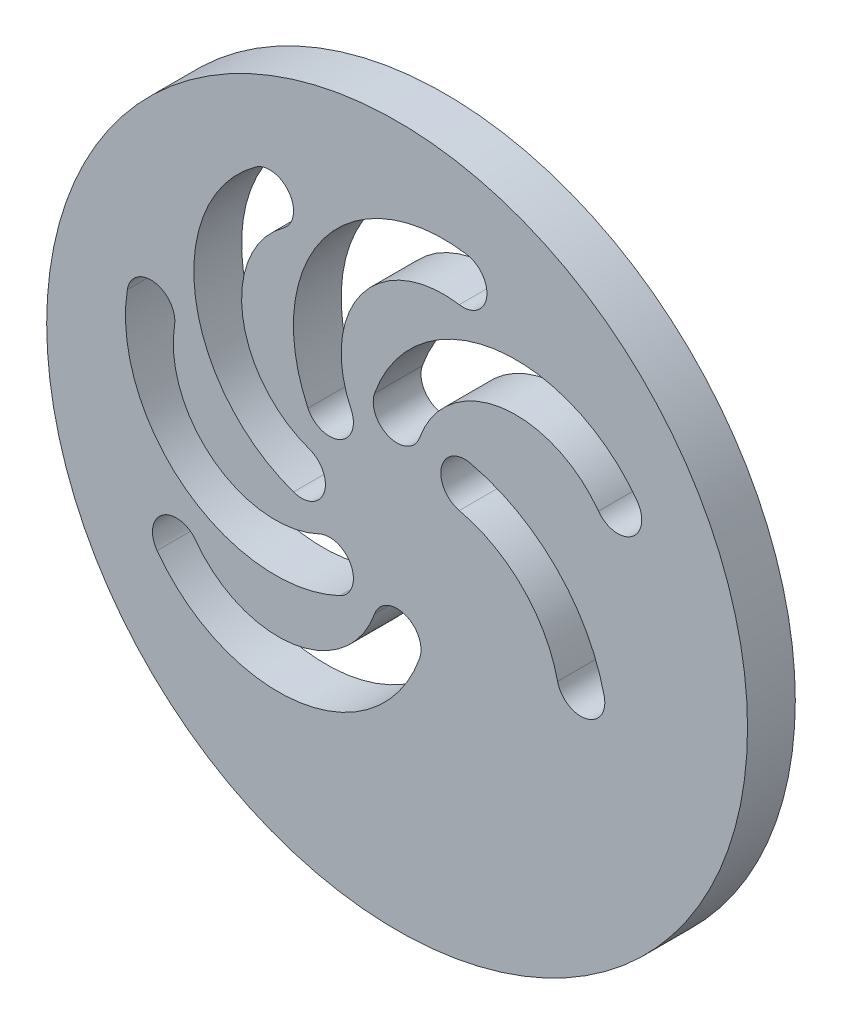
from build123d import *

# Parameters (mm, degrees)
SKETCH1_R           = 34.925
BOSS_EXTRUDE1_DEPTH = 4.7625


with BuildPart() as part:
    # Sketch1 → Boss-Extrude1 (new body)
    with BuildSketch(Plane.XY):
        Circle(SKETCH1_R)
        with BuildLine():
            ThreePointArc((2.243888697, 8.727933453), (-0.797066547, 7.281111303), (-2.243888697, 10.322066547))
            ThreePointArc((-2.243888697, 10.322066547), (9.70011878, 20.108105734), (23.923949148, 14.099068603))
            ThreePointArc((23.923949148, 14.099068603), (23.396113859, 10.773096108), (20.070141364, 11.300931397))
            ThreePointArc((20.070141364, 11.300931397), (10.380475923, 15.394453179), (2.243888697, 8.727933453))
        make_face(mode=Mode.SUBTRACT)
        with BuildLine():
            ThreePointArc((2.243888697, -10.322066547), (-9.70011878, -20.108105734), (-23.923949148, -14.099068603))
            ThreePointArc((-23.923949148, -14.099068603), (-23.396113859, -10.773096108), (-20.070141364, -11.300931397))
            ThreePointArc((-20.070141364, -11.300931397), (-10.380475923, -15.394453179), (-2.243888697, -8.727933453))
            ThreePointArc((-2.243888697, -8.727933453), (0.797066547, -7.281111303), (2.243888697, -10.322066547))
        make_face(mode=Mode.SUBTRACT)
        with BuildLine():
            ThreePointArc((-5.712134337, -8.885472165), (-21.077597689, -7.359558154), (-26.886333692, 6.947239658))
            ThreePointArc((-26.886333692, 6.947239658), (-24.161280075, 8.92582145), (-22.182698283, 6.200767833))
            ThreePointArc((-22.182698283, 6.200767833), (-18.225627153, -3.545417318), (-7.758249844, -4.584912017))
            ThreePointArc((-7.758249844, -4.584912017), (-4.584912017, -5.712134337), (-5.712134337, -8.885472165))
        make_face(mode=Mode.SUBTRACT)
        with BuildLine():
            ThreePointArc((-10.322066547, -2.243888697), (-20.108105734, 9.70011878), (-14.099068603, 23.923949148))
            ThreePointArc((-14.099068603, 23.923949148), (-10.773096108, 23.396113859), (-11.300931397, 20.070141364))
            ThreePointArc((-11.300931397, 20.070141364), (-15.394453179, 10.380475923), (-8.727933453, 2.243888697))
            ThreePointArc((-8.727933453, 2.243888697), (-7.281111303, -0.797066547), (-10.322066547, -2.243888697))
        make_face(mode=Mode.SUBTRACT)
        with BuildLine():
            ThreePointArc((-8.885472165, 5.712134337), (-7.359558154, 21.077597689), (6.947239658, 26.886333692))
            ThreePointArc((6.947239658, 26.886333692), (8.92582145, 24.161280075), (6.200767833, 22.182698283))
            ThreePointArc((6.200767833, 22.182698283), (-3.545417318, 18.225627153), (-4.584912017, 7.758249844))
            ThreePointArc((-4.584912017, 7.758249844), (-5.712134337, 4.584912017), (-8.885472165, 5.712134337))
        make_face(mode=Mode.SUBTRACT)
        with BuildLine():
            ThreePointArc((6.201017431, 4.414629875), (4.414629875, 7.269366751), (7.269366751, 9.055754306))
            ThreePointArc((7.269366751, 9.055754306), (15.894637853, 4.263683482), (20.641911756, -4.386324314))
            ThreePointArc((20.641911756, -4.386324314), (18.840742957, -7.231758214), (15.995309056, -5.430589416))
            ThreePointArc((15.995309056, -5.430589416), (12.518320569, 0.90483132), (6.201017431, 4.414629875))
        make_face(mode=Mode.SUBTRACT)
    extrude(amount=BOSS_EXTRUDE1_DEPTH)


solid = part.part
